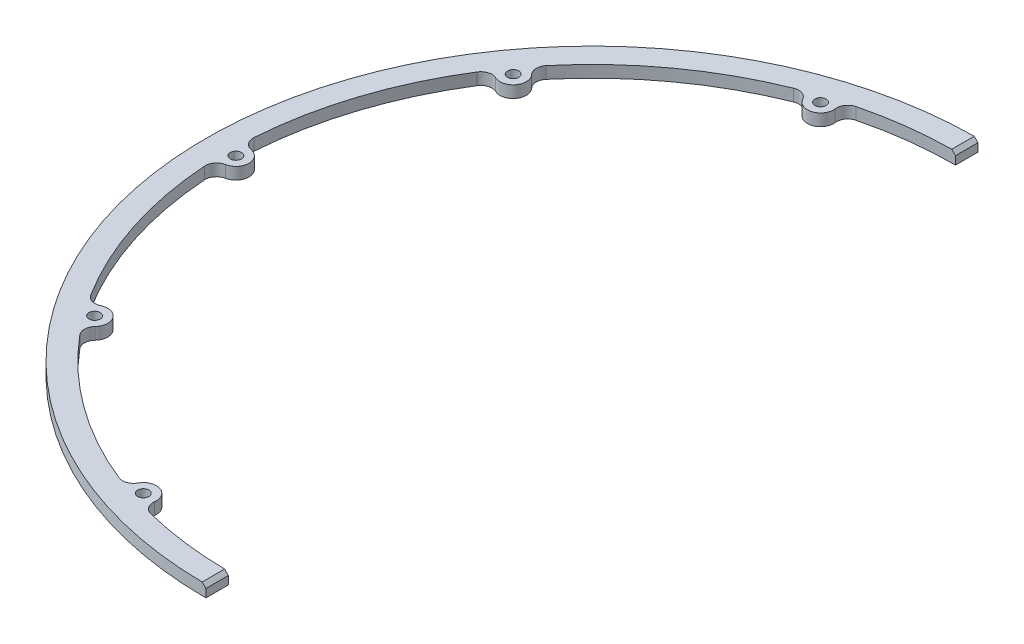
from build123d import *

# Parameters (mm, degrees)
BOSS_EXTRUDE1_DEPTH                    = 3.18
BOSS_EXTRUDE2_DEPTH                    = 3.18
FILLET1_R                              = 3
SKETCH3_R                              = 1.5
CUT_EXTRUDE1_DEPTH                     = 3.18
CIRPATTERN1_COUNT                      = 3
CIRPATTERN1_ANGLE                      = 72
FILLET1_OF_CIRPATTERN1_R               = 3
CIRPATTERN1_THE_OTHER_WAY_COUNT        = 3
CIRPATTERN1_THE_OTHER_WAY_ANGLE        = 72
FILLET1_OF_CIRPATTERN1_THE_OTHER_WAY_R = 3
CHAMFER1_SIZE                          = 1


with BuildPart() as part:
    # Sketch1 → Boss-Extrude1 (new body)
    with BuildSketch(Plane(origin=(0, 0, 0), x_dir=(1, 0, 0), z_dir=(0, 1, 0))):
        with BuildLine():
            Line((0, 103), (0, 97))
            ThreePointArc((0, 97), (-97, 0), (0, -97))
            Line((0, -97), (0, -103))
            ThreePointArc((0, -103), (-103, 0), (0, 103))
        make_face()
    extrude(amount=BOSS_EXTRUDE1_DEPTH)

    # Sketch2 → Boss-Extrude2 (add)
    with BuildSketch(Plane(origin=(0, 3.18, 0), x_dir=(1, 0, 0), z_dir=(0, 1, 0))):
        with BuildLine():
            ThreePointArc((-97.965532202, 1.858929465), (-97.515712838, 2.43334932), (-96.956578947, 2.902033567))
            ThreePointArc((-96.956578947, 2.902033567), (-96.947168056, 3.201032006), (-96.936835104, 3.5))
            Line((-96.936835104, 3.5), (-97.965532202, 1.858929465))
        make_face()
        with BuildLine():
            ThreePointArc((-96.956578947, 2.902033567), (-96.022957115, 3.347171753), (-95, 3.5))
            Line((-95, 3.5), (-96.936835104, 3.5))
            ThreePointArc((-96.936835104, 3.5), (-96.947168056, 3.201032006), (-96.956578947, 2.902033567))
        make_face()
        with BuildLine():
            Line((-97.965532202, -1.858929465), (-96.936835104, -3.5))
            ThreePointArc((-96.936835104, -3.5), (-96.947168056, -3.201032006), (-96.956578947, -2.902033567))
            ThreePointArc((-96.956578947, -2.902033567), (-97.515712838, -2.43334932), (-97.965532202, -1.858929465))
        make_face()
        with BuildLine():
            Line((-96.936835104, -3.5), (-95, -3.5))
            ThreePointArc((-95, -3.5), (-96.022957115, -3.347171753), (-96.956578947, -2.902033567))
            ThreePointArc((-96.956578947, -2.902033567), (-96.947168056, -3.201032006), (-96.936835104, -3.5))
        make_face()
        with BuildLine():
            ThreePointArc((-96.956578947, -2.902033567), (-96.022957115, -3.347171753), (-95, -3.5))
            ThreePointArc((-95, -3.5), (-92.525126266, -2.474873734), (-91.5, 0))
            ThreePointArc((-91.5, 0), (-92.525126266, 2.474873734), (-95, 3.5))
            ThreePointArc((-95, 3.5), (-96.022957115, 3.347171753), (-96.956578947, 2.902033567))
            ThreePointArc((-96.956578947, 2.902033567), (-97, 0), (-96.956578947, -2.902033567))
        make_face()
        with BuildLine():
            ThreePointArc((-97.965532202, -1.858929465), (-97.515712838, -2.43334932), (-96.956578947, -2.902033567))
            ThreePointArc((-96.956578947, -2.902033567), (-97, 0), (-96.956578947, 2.902033567))
            ThreePointArc((-96.956578947, 2.902033567), (-97.515712838, 2.43334932), (-97.965532202, 1.858929465))
            ThreePointArc((-97.965532202, 1.858929465), (-98.5, 0), (-97.965532202, -1.858929465))
        make_face()
    boss_extrude2 = extrude(amount=-BOSS_EXTRUDE2_DEPTH)

    # Fillet1
    fillet1_edges = [part.edges().sort_by_distance(p)[0] for p in [
        (-96.936835104, 1.59, -3.5),
        (-96.936835104, 1.59, 3.5),
    ]]
    fillet(fillet1_edges, radius=FILLET1_R)

    # Sketch3 → Cut-Extrude1 (cut)
    with BuildSketch(Plane(origin=(0, 3.18, 0), x_dir=(1, 0, 0), z_dir=(0, 1, 0))):
        with Locations((-95, 0)):
            Circle(SKETCH3_R)
    cut_extrude1 = extrude(amount=-CUT_EXTRUDE1_DEPTH, mode=Mode.SUBTRACT)

    # CirPattern1: Boss-Extrude2, Cut-Extrude1 ×3 about axis
    cirpattern1_axis = Axis((0, 0, 0), (0, -1, 0))
    for i in range(1, CIRPATTERN1_COUNT):
        add(boss_extrude2.rotate(cirpattern1_axis, i * CIRPATTERN1_ANGLE / (CIRPATTERN1_COUNT - 1)))
        add(cut_extrude1.rotate(cirpattern1_axis, i * CIRPATTERN1_ANGLE / (CIRPATTERN1_COUNT - 1)), mode=Mode.SUBTRACT)

    # Fillet1 of CirPattern1
    fillet1_of_cirpattern1_edges = [part.edges().sort_by_distance(p)[0] for p in [
        (-76.366298597, 1.59, -59.809601558),
        (-80.480795363, 1.59, -54.146482598),
        (-26.626431621, 1.59, -93.273968175),
        (-33.283827235, 1.59, -91.110849214),
    ]]
    fillet(fillet1_of_cirpattern1_edges, radius=FILLET1_OF_CIRPATTERN1_R)

    # CirPattern1 the other way: Boss-Extrude2, Cut-Extrude1 ×3 about axis
    cirpattern1_the_other_way_axis = Axis((0, 0, 0), (0, 1, 0))
    for i in range(1, CIRPATTERN1_THE_OTHER_WAY_COUNT):
        add(boss_extrude2.rotate(cirpattern1_the_other_way_axis, i * CIRPATTERN1_THE_OTHER_WAY_ANGLE / (CIRPATTERN1_THE_OTHER_WAY_COUNT - 1)))
        add(cut_extrude1.rotate(cirpattern1_the_other_way_axis, i * CIRPATTERN1_THE_OTHER_WAY_ANGLE / (CIRPATTERN1_THE_OTHER_WAY_COUNT - 1)), mode=Mode.SUBTRACT)

    # Fillet1 of CirPattern1 the other way
    fillet1_of_cirpattern1_the_other_way_edges = [part.edges().sort_by_distance(p)[0] for p in [
        (-80.480795363, 1.59, 54.146482598),
        (-76.366298597, 1.59, 59.809601558),
        (-33.283827235, 1.59, 91.110849214),
        (-26.626431621, 1.59, 93.273968175),
    ]]
    fillet(fillet1_of_cirpattern1_the_other_way_edges, radius=FILLET1_OF_CIRPATTERN1_THE_OTHER_WAY_R)

    # Chamfer1
    chamfer1_edges = [part.edges().sort_by_distance(p)[0] for p in [
        (0, 3.18, -100),
        (0, 3.18, 100),
    ]]
    chamfer(chamfer1_edges, length=CHAMFER1_SIZE)


solid = part.part
